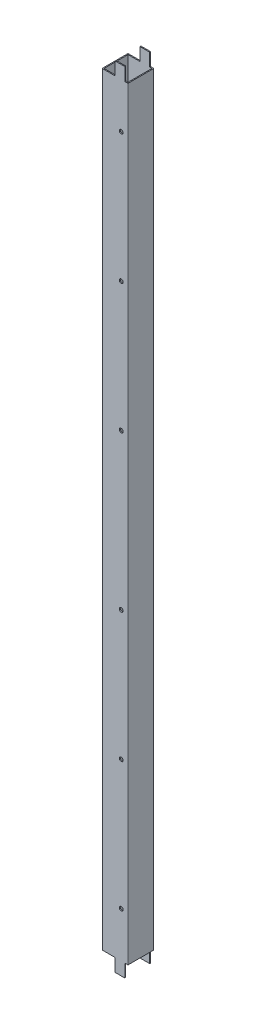
from build123d import *

# Parameters (mm, degrees)
SKETCH1_W           = 37
SKETCH1_H           = 37
BOSS_EXTRUDE1_DEPTH = 1220
SKETCH2_W           = 20
SKETCH2_H           = 20
SKETCH2_W_2         = 5
CUT_EXTRUDE1_DEPTH  = 50
SKETCH3_R           = 3
CUT_EXTRUDE2_DEPTH  = 10


with BuildPart() as part:
    # Sketch1 → Boss-Extrude1 (new body)
    with BuildSketch(Plane(origin=(0, 0, 0), x_dir=(1, 0, 0), z_dir=(0, 1, 0))):
        with BuildLine():
            Line((0.5, 0), (39.5, 0))
            ThreePointArc((39.5, 0), (39.853553391, 0.146446609), (40, 0.5))
            Line((40, 0.5), (40, 39.5))
            ThreePointArc((40, 39.5), (39.853553391, 39.853553391), (39.5, 40))
            Line((39.5, 40), (0.5, 40))
            ThreePointArc((0.5, 40), (0.146446609, 39.853553391), (0, 39.5))
            Line((0, 39.5), (0, 0.5))
            ThreePointArc((0, 0.5), (0.146446609, 0.146446609), (0.5, 0))
        make_face()
        with Locations((20, 20)):
            Rectangle(SKETCH1_W, SKETCH1_H, mode=Mode.SUBTRACT)
    extrude(amount=BOSS_EXTRUDE1_DEPTH)

    # Sketch2 → Cut-Extrude1 (cut)
    with BuildSketch(Plane.XY):
        with Locations((10, 1210)):
            Rectangle(SKETCH2_W, SKETCH2_H)
        with Locations((37.5, 1210)):
            Rectangle(SKETCH2_W_2, SKETCH2_H)
        with Locations((10, 10)):
            Rectangle(SKETCH2_W, SKETCH2_H)
        with Locations((37.5, 10)):
            Rectangle(SKETCH2_W_2, SKETCH2_H)
    extrude(amount=-CUT_EXTRUDE1_DEPTH, mode=Mode.SUBTRACT)

    # Sketch3 → Cut-Extrude2 (cut)
    with BuildSketch(Plane.XY):
        with Locations((29.5, 90)):
            Circle(SKETCH3_R)
        with Locations((29.5, 290)):
            Circle(SKETCH3_R)
        with Locations((29.5, 490)):
            Circle(SKETCH3_R)
        with Locations(Location((29.5, 730, 0), (0, 0, 180))):
            Circle(SKETCH3_R)
        with Locations(Location((29.5, 930, 0), (0, 0, 180))):
            Circle(SKETCH3_R)
        with Locations(Location((29.5, 1130, 0), (0, 0, 180))):
            Circle(SKETCH3_R)
    extrude(amount=-CUT_EXTRUDE2_DEPTH, mode=Mode.SUBTRACT)


solid = part.part
